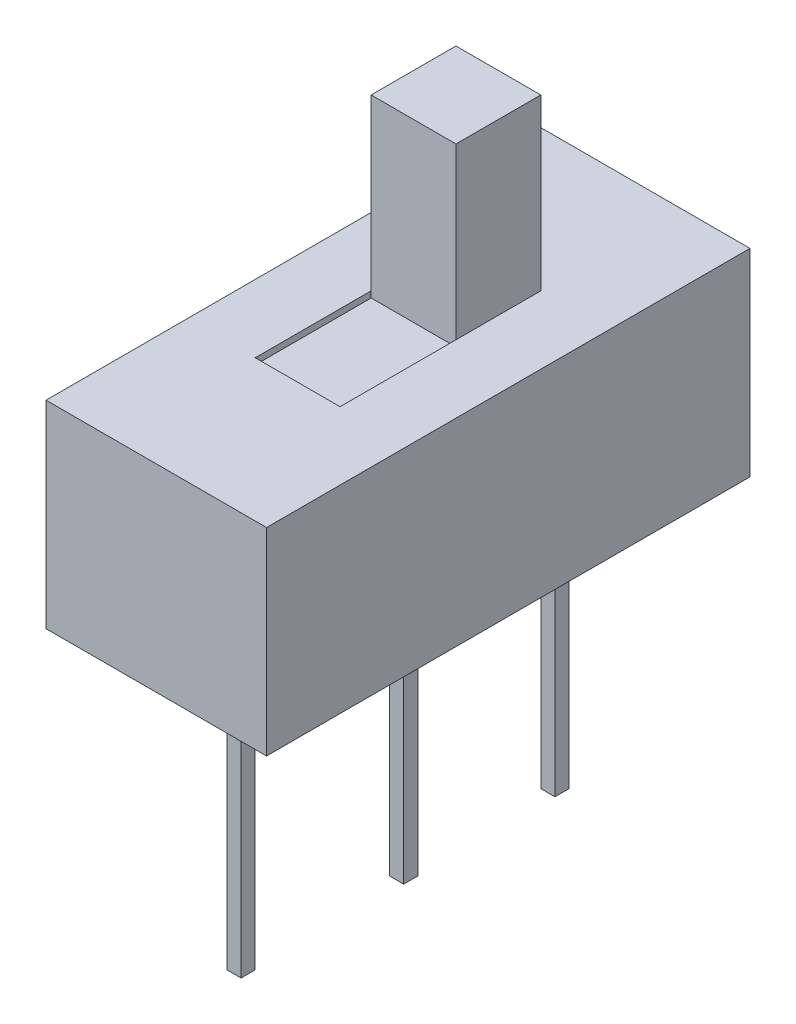
from build123d import *

# Parameters (mm, degrees)
SKETCH1_W           = 3.9
SKETCH1_H           = 8.55
BOSS_EXTRUDE1_DEPTH = 3.5
SKETCH2_W           = 1.5
SKETCH2_H           = 3
BOSS_EXTRUDE2_DEPTH = 1.5
SKETCH3_W           = 2.05
SKETCH3_H           = 0.11
CUT_EXTRUDE1_DEPTH  = 1.5
SKETCH4_W           = 0.25
SKETCH4_H           = 0.25
BOSS_EXTRUDE3_DEPTH = 5
SKETCH5_W           = 0.25
SKETCH5_H           = 0.25
BOSS_EXTRUDE4_DEPTH = 5
SKETCH6_W           = 0.25
SKETCH6_H           = 0.25
BOSS_EXTRUDE5_DEPTH = 5


with BuildPart() as part:
    # Sketch1 → Boss-Extrude1 (new body)
    with BuildSketch(Plane(origin=(0, 3.5, 0), x_dir=(1, 0, 0), z_dir=(0, 1, 0))):
        with Locations((1.95, 4.275)):
            Rectangle(SKETCH1_W, SKETCH1_H)
    extrude(amount=-BOSS_EXTRUDE1_DEPTH)

    # Sketch2 → Boss-Extrude2 (add)
    with BuildSketch(Plane(origin=(2.7, 0, 0), x_dir=(0, 0, -1), z_dir=(1, 0, 0))):
        with Locations((5.3, 5)):
            Rectangle(SKETCH2_W, SKETCH2_H)
    extrude(amount=-BOSS_EXTRUDE2_DEPTH)

    # Sketch3 → Cut-Extrude1 (cut)
    with BuildSketch(Plane(origin=(2.7, 0, 0), x_dir=(0, 0, -1), z_dir=(1, 0, 0))):
        with Locations((3.525, 3.445)):
            Rectangle(SKETCH3_W, SKETCH3_H)
    extrude(amount=-CUT_EXTRUDE1_DEPTH, mode=Mode.SUBTRACT)

    # Sketch4 → Boss-Extrude3 (add)
    with BuildSketch(Plane.XZ):
        with Locations((1.95, -7.05)):
            Rectangle(SKETCH4_W, SKETCH4_H)
    extrude(amount=BOSS_EXTRUDE3_DEPTH)

    # Sketch5 → Boss-Extrude4 (add)
    with BuildSketch(Plane.XZ):
        with Locations((1.95, -1.5)):
            Rectangle(SKETCH5_W, SKETCH5_H)
    extrude(amount=BOSS_EXTRUDE4_DEPTH)

    # Sketch6 → Boss-Extrude5 (add)
    with BuildSketch(Plane.XZ):
        with Locations((1.95, -4.375)):
            Rectangle(SKETCH6_W, SKETCH6_H)
    extrude(amount=BOSS_EXTRUDE5_DEPTH)


solid = part.part
